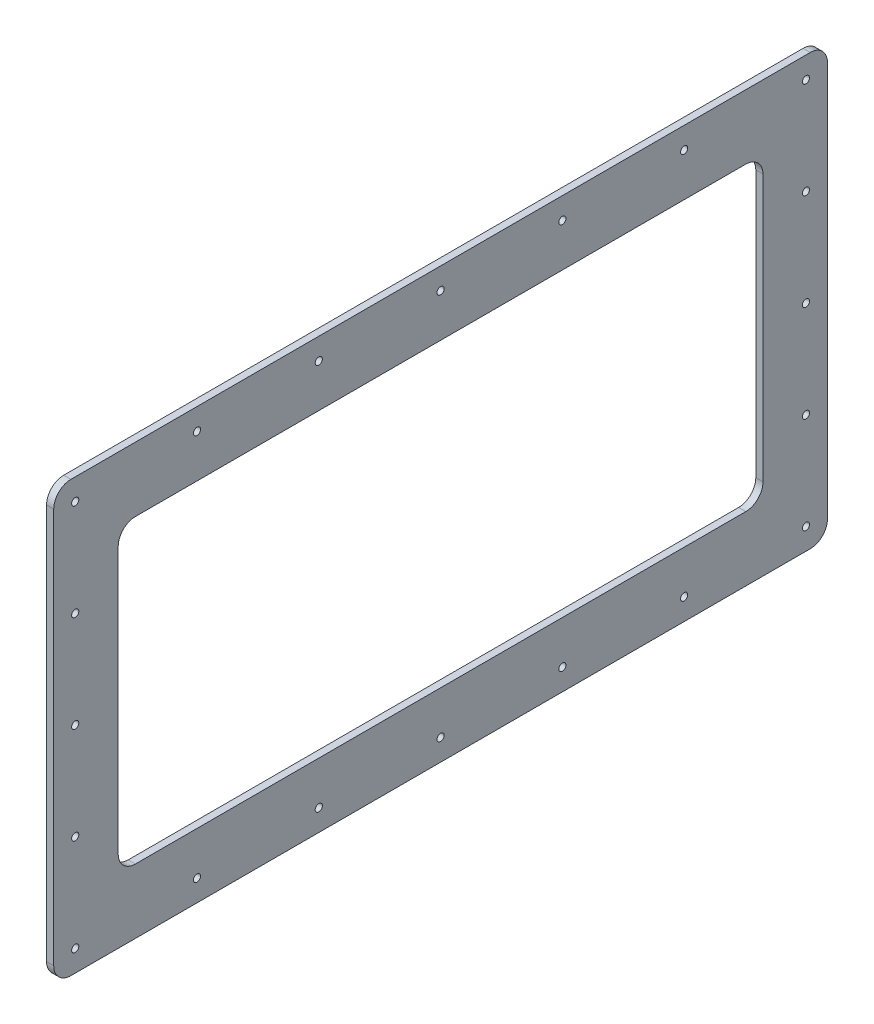
from build123d import *

# Parameters (mm, degrees)
BOSS_EXTRUDE1_START         = 12.7
SKETCH1_W                   = 685.8
SKETCH1_H                   = 381
SKETCH1_W_2                 = 571.5
SKETCH1_H_2                 = 266.7
BOSS_EXTRUDE1_DEPTH         = 6.35
F_1_4_0_25_DIAMETER_HOLE1_D = 6.35
LPATTERN2_COUNT             = 7
LPATTERN2_PITCH             = 107.95
LPATTERN2_COUNT_DIR2        = 5
LPATTERN2_PITCH_DIR2        = 85.725
FILLET1_R                   = 15.24


with BuildPart() as part:
    # Sketch1 → Boss-Extrude1 (new body)
    with BuildSketch(Plane.ZY.offset(311.15).offset(BOSS_EXTRUDE1_START)):
        with Locations((0, 330.2)):
            Rectangle(SKETCH1_W, SKETCH1_H)
        with Locations((0, 330.2)):
            Rectangle(SKETCH1_W_2, SKETCH1_H_2, mode=Mode.SUBTRACT)
    extrude(amount=BOSS_EXTRUDE1_DEPTH)

    # 1/4 (0.25) Diameter Hole1 (through all)
    with Locations(Plane.ZY.offset(330.2)):
        with Locations((-323.85, 158.75)):
            f_1_4_0_25_diameter_hole1 = Hole(F_1_4_0_25_DIAMETER_HOLE1_D / 2)

    # LPattern2: 1_4 _0.25_ Diameter Hole1 7 × 5, 15 skipped
    with Locations(*[(0, j * LPATTERN2_PITCH_DIR2, i * LPATTERN2_PITCH) for i in range(LPATTERN2_COUNT) for j in range(LPATTERN2_COUNT_DIR2) if (i, j) not in ((0, 0), (1, 1), (1, 2), (1, 3), (2, 1), (2, 2), (2, 3), (3, 1), (3, 2), (3, 3), (4, 1), (4, 2), (4, 3), (5, 1), (5, 2), (5, 3))]):
        add(f_1_4_0_25_diameter_hole1, mode=Mode.SUBTRACT)

    # Fillet1
    fillet1_edges = [part.edges().sort_by_distance(p)[0] for p in [
        (-327.025, 463.55, -285.75),
        (-327.025, 196.85, -285.75),
        (-327.025, 196.85, 285.75),
        (-327.025, 463.55, 285.75),
        (-327.025, 520.7, -342.9),
        (-327.025, 520.7, 342.9),
        (-327.025, 139.7, 342.9),
        (-327.025, 139.7, -342.9),
    ]]
    fillet(fillet1_edges, radius=FILLET1_R)


solid = part.part
